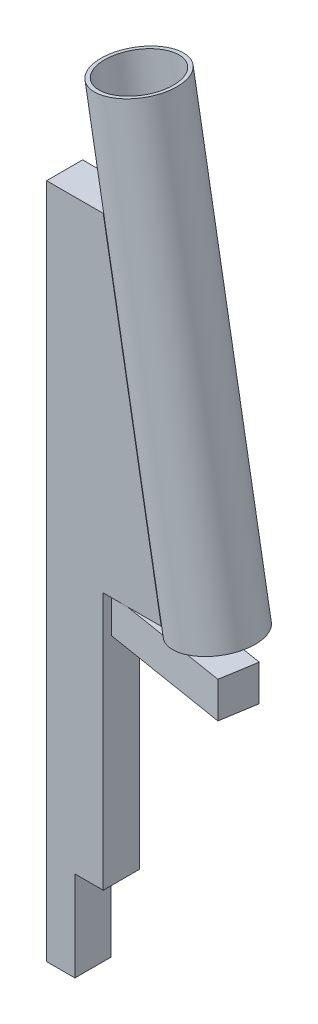
from build123d import *

# Parameters (mm, degrees)
MAIN_EXTRUSION_DEPTH = 14
LOCK_EXTRUSION_DEPTH = 28
ESQUISSE3_R          = 30
ESQUISSE3_R_2        = 27
PLEXIGLAS_DEPTH      = 350


with BuildPart() as part:
    # Esquisse1 → Main Extrusion (new body, symmetric)
    with BuildSketch(Plane.XY):
        Polygon((0, 525.207681883), (0, 0), (22, 0), (22, 70), (44, 70), (44, 270), (89, 270), (44, 525.207681883), align=None)
    extrude(amount=MAIN_EXTRUSION_DEPTH, both=True)

    # Esquisse2 → Lock Extrusion (add)
    with BuildSketch(Plane(origin=(0, 270, 0), x_dir=(-1, 0, 0), z_dir=(0, -1, 0))):
        Polygon((-47.932439792, -11.56864335), (-146.633166785, -27.636203558), (-151.132083643, 0), (-52.43135665, 16.067560208), align=None)
    extrude(amount=LOCK_EXTRUSION_DEPTH)


with BuildPart() as body_2:
    # Esquisse3 → Plexiglas (new body)
    with BuildSketch(Plane(origin=(-43.489040974, 246.638607428, 0), x_dir=(0, 0, -1), z_dir=(0.173648178, -0.984807753, 0))):
        with Locations((0, 164.532897988)):
            Circle(ESQUISSE3_R)
        with Locations((0, 164.532897988)):
            Circle(ESQUISSE3_R_2, mode=Mode.SUBTRACT)
    extrude(amount=-PLEXIGLAS_DEPTH)


solid = Compound([part.part, body_2.part])
